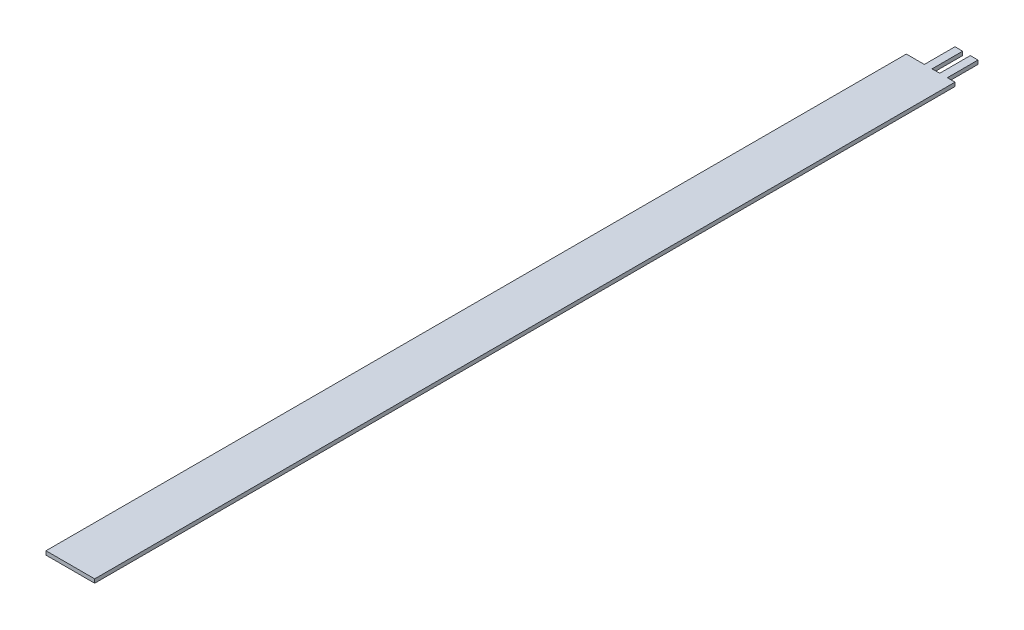
from build123d import *

# Parameters (mm, degrees)
SKETCH1_W           = 6.35
SKETCH1_H           = 112.24
BOSS_EXTRUDE1_DEPTH = 0.5
BOSS_EXTRUDE2_DEPTH = 4


with BuildPart() as part:
    # Sketch1 → Boss-Extrude1 (new body)
    with BuildSketch(Plane(origin=(0, 0, 0), x_dir=(1, 0, 0), z_dir=(0, 1, 0))):
        with Locations((3.175, -56.12)):
            Rectangle(SKETCH1_W, SKETCH1_H)
    extrude(amount=BOSS_EXTRUDE1_DEPTH)

    # Sketch2 → Boss-Extrude2 (add)
    with BuildSketch(Plane(origin=(0, 0, 0), x_dir=(-1, 0, 0), z_dir=(0, 0, -1))):
        Polygon((-2.35, 0.5), (-3.35, 0.5), (-3.35, 0.25), (-3.35, 0), (-2.35, 0), align=None)
        Polygon((-4.35, 0.5), (-5.35, 0.5), (-5.35, 0), (-4.35, 0), (-4.35, 0.25), align=None)
    extrude(amount=BOSS_EXTRUDE2_DEPTH)


solid = part.part
